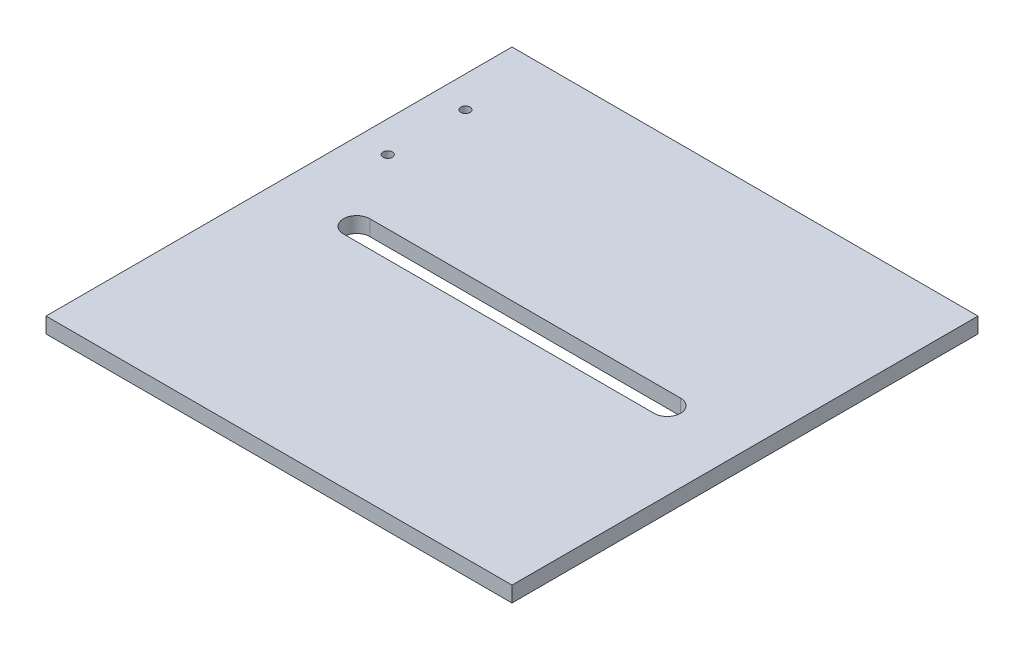
from build123d import *

# Parameters (mm, degrees)
SKETCH1_W           = 150
SKETCH1_H           = 150
SKETCH1_R           = 1.5
BOSS_EXTRUDE1_DEPTH = 5


with BuildPart() as part:
    # Sketch1 → Boss-Extrude1 (new body)
    with BuildSketch(Plane(origin=(0, 0, 0), x_dir=(1, 0, 0), z_dir=(0, 1, 0))):
        with Locations((75, 75)):
            Rectangle(SKETCH1_W, SKETCH1_H)
        with Locations((10, 125)):
            Circle(SKETCH1_R, mode=Mode.SUBTRACT)
        with Locations((10, 100)):
            Circle(SKETCH1_R, mode=Mode.SUBTRACT)
        with BuildLine():
            Line((25, 79.25), (125, 79.25))
            ThreePointArc((125, 79.25), (129.25, 75), (125, 70.75))
            Line((125, 70.75), (25, 70.75))
            ThreePointArc((25, 70.75), (20.75, 75), (25, 79.25))
        make_face(mode=Mode.SUBTRACT)
    extrude(amount=BOSS_EXTRUDE1_DEPTH)


solid = part.part
